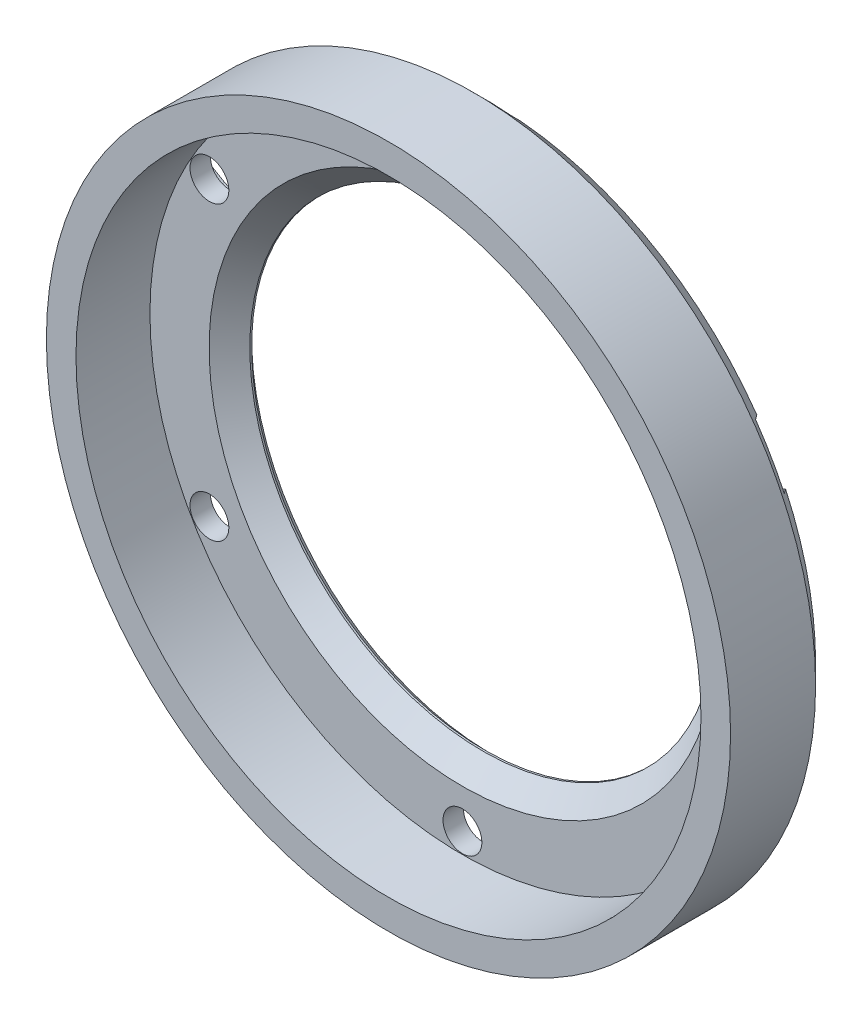
from build123d import *

# Parameters (mm, degrees)
SKETCH1_R           = 18.5
BOSS_EXTRUDE1_DEPTH = 5.6
SHELL1_T            = -1.6
SKETCH2_R           = 12.6
CUT_EXTRUDE1_DEPTH  = 27.75556017
SKETCH3_R           = 1.05
CUT_EXTRUDE3_DEPTH  = 27.75556017
CIRPATTERN1_COUNT   = 6
CHAMFER1_SIZE       = 1
CUT_EXTRUDE4_DEPTH  = 0.5
CIRPATTERN2_COUNT   = 6
CHAMFER2_SIZE       = 0.4
CHAMFER3_SIZE       = 1.1


with BuildPart() as part:
    # Sketch1 → Boss-Extrude1 (new body)
    with BuildSketch(Plane.XY):
        Circle(SKETCH1_R)
    extrude(amount=BOSS_EXTRUDE1_DEPTH)

    # Shell1
    shell1_openings = [part.faces().sort_by_distance(p)[0] for p in [
        (0, 0, 5.6),
    ]]
    offset(amount=SHELL1_T, openings=shell1_openings, kind=Kind.INTERSECTION)

    # Sketch2 → Cut-Extrude1 (cut, through all)
    with BuildSketch(Plane(origin=(0, 0, 0), x_dir=(-1, 0, 0), z_dir=(0, 0, -1))):
        Circle(SKETCH2_R)
    extrude(amount=-CUT_EXTRUDE1_DEPTH, mode=Mode.SUBTRACT)

    # Sketch3 → Cut-Extrude3 (cut, through all)
    with BuildSketch(Plane.XY):
        with Locations((0, 15.8)):
            Circle(SKETCH3_R)
    cut_extrude3 = extrude(amount=CUT_EXTRUDE3_DEPTH, mode=Mode.SUBTRACT)

    # CirPattern1: Cut-Extrude3 ×6 about axis
    cirpattern1_axis = Axis((0, 0, 0), (0, 0, 1))
    for i in range(1, CIRPATTERN1_COUNT):
        add(cut_extrude3.rotate(cirpattern1_axis, i * 360 / CIRPATTERN1_COUNT), mode=Mode.SUBTRACT)

    # Chamfer1
    chamfer1_edges = [part.edges().sort_by_distance(p)[0] for p in [
        (-18.5, 0, 0),
    ]]
    chamfer(chamfer1_edges, length=CHAMFER1_SIZE)

    # Sketch4 → Cut-Extrude4 (cut)
    with BuildSketch(Plane(origin=(0, 0, 0), x_dir=(-1, 0, 0), z_dir=(0, 0, -1))):
        with BuildLine():
            Line((-1.55, -15.8), (-1.55, -18.667530629))
            Line((-1.55, -18.667530629), (1.55, -18.667530629))
            Line((1.55, -18.667530629), (1.55, -15.8))
            ThreePointArc((1.55, -15.8), (0, -14.25), (-1.55, -15.8))
        make_face()
    cut_extrude4 = extrude(amount=-CUT_EXTRUDE4_DEPTH, mode=Mode.SUBTRACT)

    # CirPattern2: Cut-Extrude4 ×6 about axis
    cirpattern2_axis = Axis((0, 0, 0), (0, 0, 1))
    for i in range(1, CIRPATTERN2_COUNT):
        add(cut_extrude4.rotate(cirpattern2_axis, i * 360 / CIRPATTERN2_COUNT), mode=Mode.SUBTRACT)

    # Chamfer2
    chamfer2_edges = [part.edges().sort_by_distance(p)[0] for p in [
        (12.6, 0, 0),
    ]]
    chamfer(chamfer2_edges, length=CHAMFER2_SIZE)

    # Chamfer3
    chamfer3_edges = [part.edges().sort_by_distance(p)[0] for p in [
        (12.6, 0, 1.6),
    ]]
    chamfer(chamfer3_edges, length=CHAMFER3_SIZE)


solid = part.part
